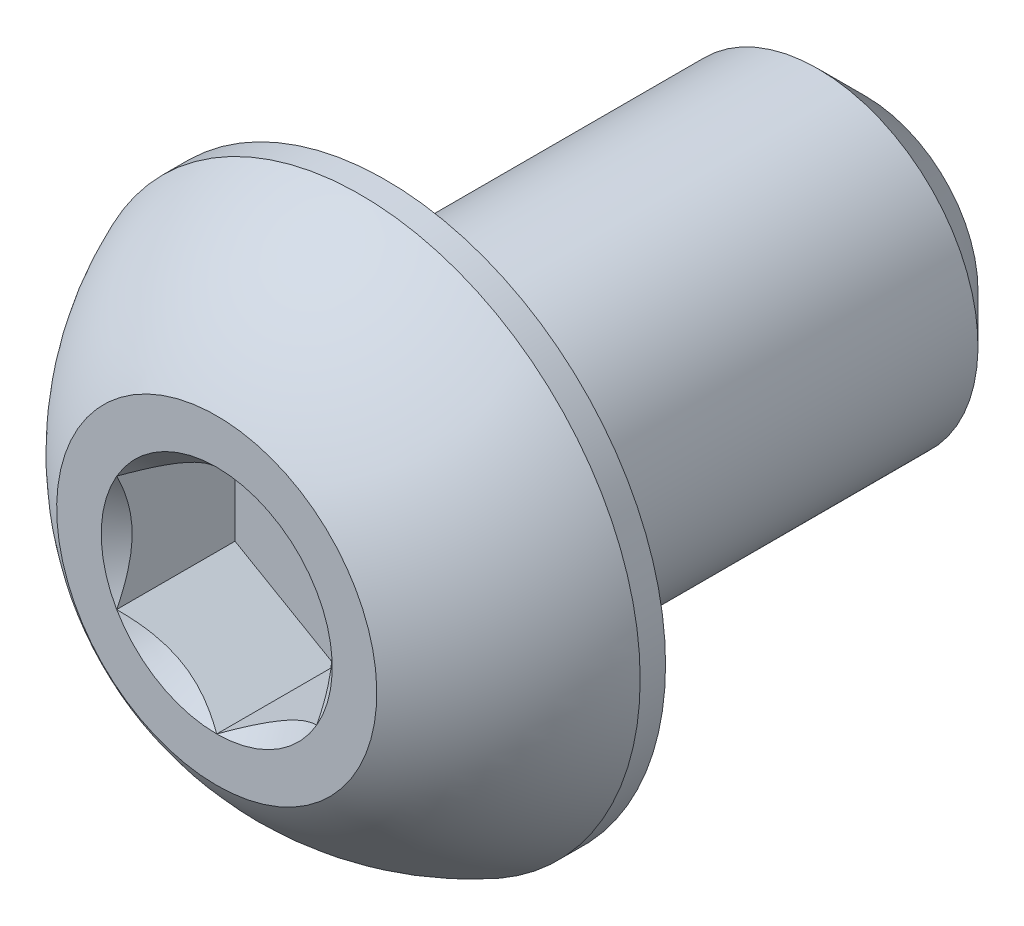
from build123d import *

# Parameters (mm, degrees)
SKETCH1_W          = 9.525
SKETCH1_H          = 3.175
CHAMFER1_SIZE      = 0.9525
CUT_EXTRUDE2_DEPTH = 2.34696


with BuildPart() as part:
    # Sketch1 → Revolve1 (revolve)
    with BuildSketch(Plane(origin=(0, 0, 0), x_dir=(0, 0, -1), z_dir=(1, 0, 0))):
        with Locations((8.1153, 1.5875)):
            Rectangle(SKETCH1_W, SKETCH1_H)
    revolve(axis=Axis((0, 0, -12.8778), (0, 0, 1)))

    # Chamfer1
    chamfer1_edges = [part.edges().sort_by_distance(p)[0] for p in [
        (0, -3.175, -12.8778),
    ]]
    chamfer(chamfer1_edges, length=CHAMFER1_SIZE)

    # Sketch7 → Revolve2 (revolve)
    with BuildSketch(Plane(origin=(0, 0, 0), x_dir=(0, 0, -1), z_dir=(1, 0, 0))):
        with BuildLine():
            Line((2.84988, 5.5499), (3.3528, 5.5499))
            Line((3.3528, 5.5499), (3.3528, 0))
            Line((3.3528, 0), (0, 0))
            Line((0, 0), (0, 3.175))
            ThreePointArc((0, 3.175), (1.235921075, 4.58927271), (2.84988, 5.5499))
        make_face()
    revolve(axis=Axis((0, 0, 0), (0, 0, -1)))

    # Sketch5 → Cut-Extrude2 (cut)
    with BuildSketch(Plane.XY):
        Polygon((1.984375, -1.14567944), (1.984375, 1.14567944), (0, 2.291358881), (-1.984375, 1.14567944), (-1.984375, -1.14567944), (0, -2.291358881), align=None)
    extrude(amount=-CUT_EXTRUDE2_DEPTH, mode=Mode.SUBTRACT)

    # Cut-Extrude3 cone 1 section (through the dimple's axis) → Cut-Extrude3 (revolve, cut)
    with BuildSketch(Plane(origin=(0, 0, 0), x_dir=(0, -1, 0), z_dir=(1, 0, 0))):
        Polygon((0, 0), (2.291358881, 0), (0, 2.291358881), align=None)
    revolve(axis=Axis((0, 0, 0), (0, 0, -1)), mode=Mode.SUBTRACT)


solid = part.part
